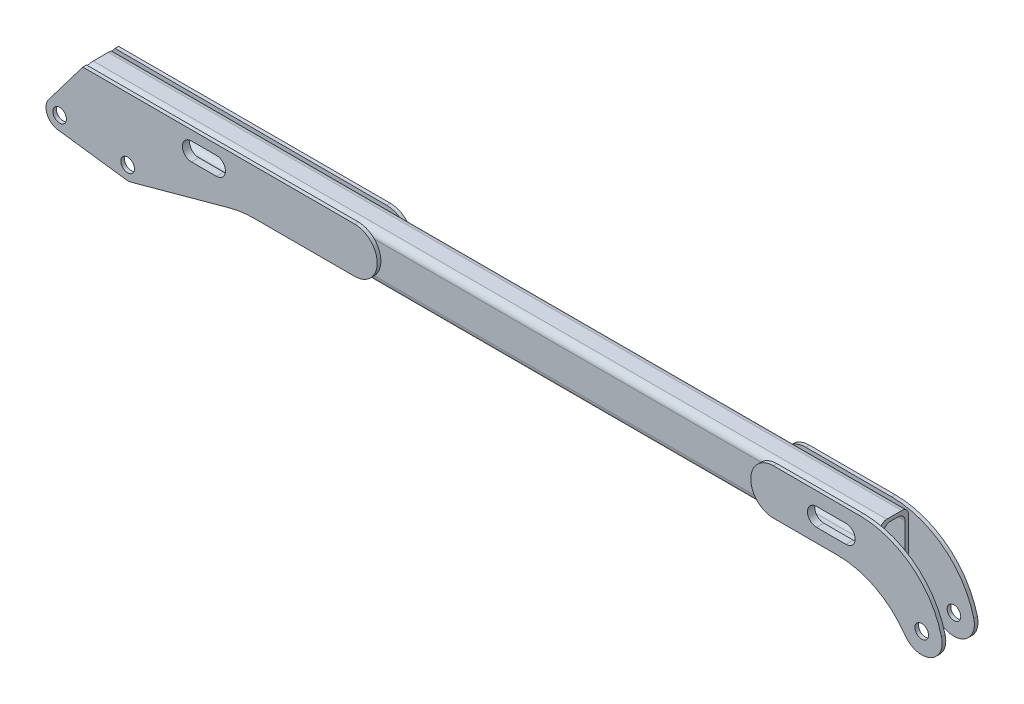
from build123d import *

# Parameters (mm, degrees)
SKETCH3_W           = 63
SKETCH3_H           = 100
SKETCH3_W_2         = 47
SKETCH3_H_2         = 84
BOSS_EXTRUDE1_DEPTH = 1800
FILLET1_R           = 15
SKETCH4_R           = 15
BOSS_EXTRUDE2_DEPTH = 8
CUT_EXTRUDE3_DEPTH  = 80
CUT_EXTRUDE5_DEPTH  = 63
SKETCH8_R           = 15
BOSS_EXTRUDE3_DEPTH = 8
CUT_EXTRUDE6_DEPTH  = 80.0000001


with BuildPart() as part:
    # Sketch3 → Boss-Extrude1 (new body)
    with BuildSketch(Plane(origin=(0, 0, 0), x_dir=(0, 0, -1), z_dir=(1, 0, 0))):
        with Locations((0, 67.5)):
            Rectangle(SKETCH3_W, SKETCH3_H)
        with Locations((0, 67.5)):
            Rectangle(SKETCH3_W_2, SKETCH3_H_2, mode=Mode.SUBTRACT)
    extrude(amount=BOSS_EXTRUDE1_DEPTH)

    # Fillet1
    fillet1_edges = [part.edges().sort_by_distance(p)[0] for p in [
        (900, 109.5, 23.5),
        (900, 25.5, 23.5),
        (900, 25.5, -23.5),
        (900, 109.5, -23.5),
        (900, 17.5, -31.5),
        (900, 17.5, 31.5),
        (900, 117.5, 31.5),
        (900, 117.5, -31.5),
    ]]
    fillet(fillet1_edges, radius=FILLET1_R)

    # Sketch4 → Boss-Extrude2 (add)
    with BuildSketch(Plane.XY.offset(31.5)):
        with BuildLine():
            Line((51.132453633, 117.5), (-23.941241068, 18.07807999))
            ThreePointArc((-23.941241068, 18.07807999), (-27.681309785, -11.564821166), (-3.964911603, -29.73683702))
            Line((-3.964911603, -29.73683702), (146.035088397, -49.73683702))
            ThreePointArc((146.035088397, -49.73683702), (152.009214612, -49.932641992), (157.903578304, -48.940170179))
            Line((157.903578304, -48.940170179), (375.312967218, 10.434467861))
            ThreePointArc((375.312967218, 10.434467861), (401.42242053, 15.725747031), (428.003489242, 17.5))
            Line((428.003489242, 17.5), (650, 17.5))
            ThreePointArc((650, 17.5), (700, 67.5), (650, 117.5))
            Line((650, 117.5), (51.132453633, 117.5))
        make_face()
        Circle(SKETCH4_R, mode=Mode.SUBTRACT)
        with Locations((150, -20)):
            Circle(SKETCH4_R, mode=Mode.SUBTRACT)
    boss_extrude2 = extrude(amount=BOSS_EXTRUDE2_DEPTH)

    # Mirror2: Boss-Extrude2 across plane
    add(boss_extrude2.mirror(Plane.XY))

    # Sketch5 → Cut-Extrude3 (cut, through all)
    with BuildSketch(Plane.XY.offset(39.5)):
        with BuildLine():
            Line((290.508026136, 96.142023945), (345.508026136, 96.142023945))
            ThreePointArc((345.508026136, 96.142023945), (365.508026136, 76.142023945), (345.508026136, 56.142023945))
            Line((345.508026136, 56.142023945), (290.508026136, 56.142023945))
            ThreePointArc((290.508026136, 56.142023945), (270.508026136, 76.142023945), (290.508026136, 96.142023945))
        make_face()
    extrude(amount=-CUT_EXTRUDE3_DEPTH, mode=Mode.SUBTRACT)

    # Sketch7 → Cut-Extrude5 (cut)
    with BuildSketch(Plane.XY.offset(31.5)):
        Polygon((0, 17.5), (51.132453633, 117.5), (-2.794234501, 117.5), (-2.794234501, 17.5), align=None)
    extrude(amount=-CUT_EXTRUDE5_DEPTH, mode=Mode.SUBTRACT)

    # Sketch8 → Boss-Extrude3 (add)
    with BuildSketch(Plane.XY.offset(31.5)):
        with BuildLine():
            Line((1573.208774734, 17.5), (1714.67806612, 17.5))
            ThreePointArc((1714.67806612, 17.5), (1798.428366058, -3.186841446), (1862.91487867, -60.489091313))
            ThreePointArc((1862.91487867, -60.489091313), (1918.389175604, -76.071136101), (1943.712509929, -24.312789154))
            ThreePointArc((1943.712509929, -24.312789154), (1877.887370152, 77.812206283), (1763.051214044, 117.5))
            Line((1763.051214044, 117.5), (1573.208774734, 117.5))
            ThreePointArc((1573.208774734, 117.5), (1523.208774734, 67.5), (1573.208774734, 17.5))
        make_face()
        with Locations((1900, -35)):
            Circle(SKETCH8_R, mode=Mode.SUBTRACT)
    boss_extrude3 = extrude(amount=BOSS_EXTRUDE3_DEPTH)

    # Mirror8: Boss-Extrude3 across plane
    add(boss_extrude3.mirror(Plane.XY))

    # Sketch9 → Cut-Extrude6 (cut, through all)
    with BuildSketch(Plane.XY.offset(39.5)):
        with BuildLine():
            Line((1668.198215583, 87.5), (1733.198215583, 87.5))
            ThreePointArc((1733.198215583, 87.5), (1753.198215583, 67.5), (1733.198215583, 47.5))
            Line((1733.198215583, 47.5), (1668.198215583, 47.5))
            ThreePointArc((1668.198215583, 47.5), (1648.198215583, 67.5), (1668.198215583, 87.5))
        make_face()
    extrude(amount=-CUT_EXTRUDE6_DEPTH, mode=Mode.SUBTRACT)


solid = part.part
